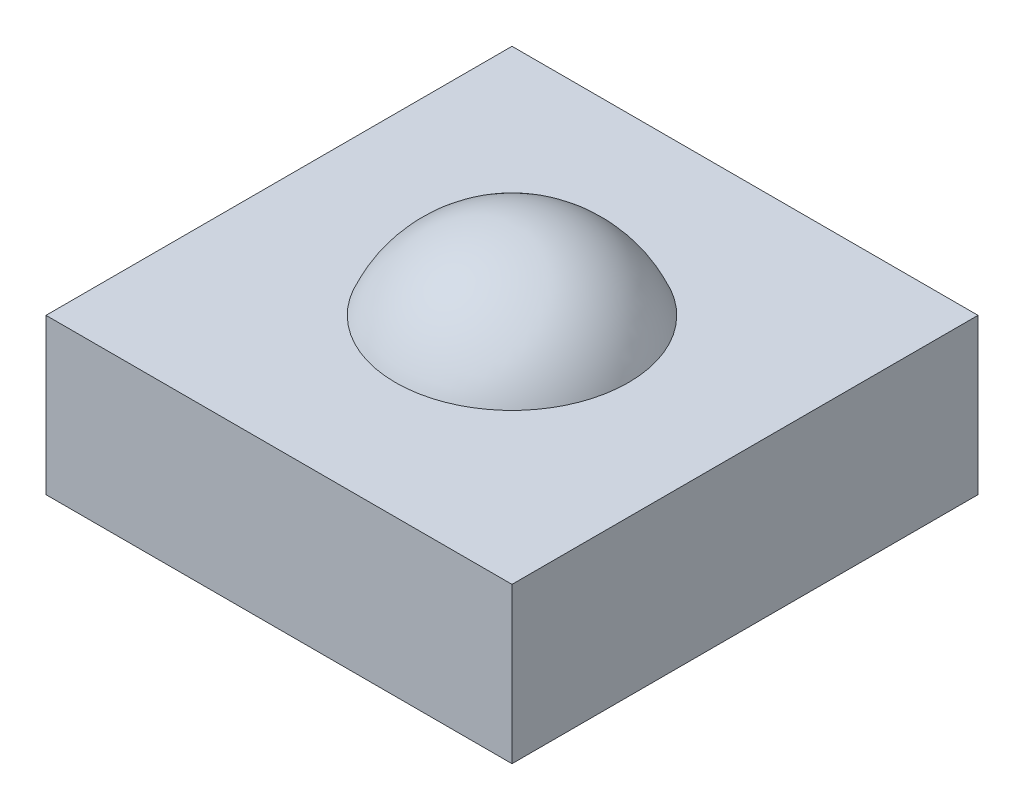
from build123d import *

# Parameters (mm, degrees)
SKETCH1_W           = 0.6
SKETCH1_H           = 0.6
BOSS_EXTRUDE1_DEPTH = 0.2


with BuildPart() as part:
    # Sketch1 → Boss-Extrude1 (new body)
    with BuildSketch(Plane(origin=(0, 0, 0), x_dir=(1, 0, 0), z_dir=(0, 1, 0))):
        Rectangle(SKETCH1_W, SKETCH1_H)
    extrude(amount=BOSS_EXTRUDE1_DEPTH)

    # Sketch2 → Revolve1 (revolve)
    with BuildSketch(Plane.XY):
        with BuildLine():
            Line((0, 0.2), (0.15, 0.2))
            ThreePointArc((0.15, 0.2), (0.090138782, 0.272708173), (0, 0.3))
            Line((0, 0.3), (0, 0.2))
        make_face()
    revolve(axis=Axis((0, 0.2, 0), (0, 1, 0)))


solid = part.part
